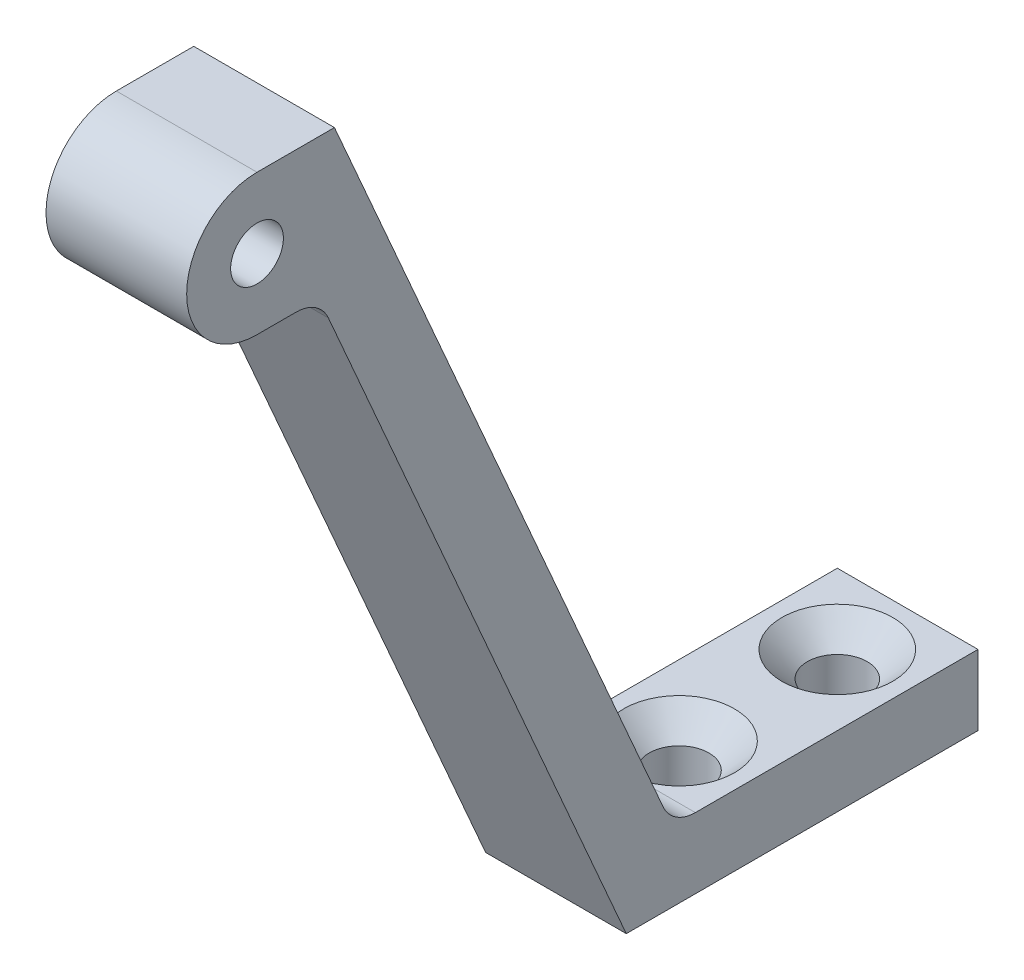
from build123d import *

# Parameters (mm, degrees)
SKETCH1_R                                       = 1.5
BOSS_EXTRUDE1_DEPTH                             = 4
CSK_FOR_M3_FLAT_HEAD_MACHINE_SCREW1_D           = 3.4
CSK_FOR_M3_FLAT_HEAD_MACHINE_SCREW1_DEPTH       = 7.5
CSK_FOR_M3_FLAT_HEAD_MACHINE_SCREW1_CSINK_D     = 6.3
CSK_FOR_M3_FLAT_HEAD_MACHINE_SCREW1_CSINK_ANGLE = 90
CSK_FOR_M3_FLAT_HEAD_MACHINE_SCREW1_TIP         = 1.021463052
FILLET1_R                                       = 2


with BuildPart() as part:
    # Sketch1 → Boss-Extrude1 (new body, symmetric)
    with BuildSketch(Plane(origin=(0, 0, 0), x_dir=(0, 0, -1), z_dir=(1, 0, 0))):
        with BuildLine():
            Line((0, -0.882843337), (0, 0))
            Line((0, 0), (0, 3.117156663))
            Line((0, 3.117156663), (-17.3820744, 3.117156663))
            Line((-17.3820744, 3.117156663), (-36.597884255, 47.117156663))
            Line((-36.597884255, 47.117156663), (-41, 47.117156663))
            ThreePointArc((-41, 47.117156663), (-45, 43.117156663), (-41, 39.117156663))
            Line((-41, 39.117156663), (-37.46891805, 39.117156663))
            Line((-37.46891805, 39.117156663), (-20, -0.882843337))
            Line((-20, -0.882843337), (0, -0.882843337))
        make_face()
        with Locations((-41, 43.117156663)):
            Circle(SKETCH1_R, mode=Mode.SUBTRACT)
    extrude(amount=BOSS_EXTRUDE1_DEPTH, both=True)

    # CSK for M3 Flat Head Machine Screw1
    with Locations(Plane(origin=(0, 3.117156663, 0), x_dir=(1, 0, 0), z_dir=(0, 1, 0))):
        with Locations((0, -13), (0, -4)):
            CounterSinkHole(CSK_FOR_M3_FLAT_HEAD_MACHINE_SCREW1_D / 2, CSK_FOR_M3_FLAT_HEAD_MACHINE_SCREW1_CSINK_D / 2, depth=CSK_FOR_M3_FLAT_HEAD_MACHINE_SCREW1_DEPTH, counter_sink_angle=CSK_FOR_M3_FLAT_HEAD_MACHINE_SCREW1_CSINK_ANGLE)
            with Locations((0, 0, -(CSK_FOR_M3_FLAT_HEAD_MACHINE_SCREW1_DEPTH + CSK_FOR_M3_FLAT_HEAD_MACHINE_SCREW1_TIP / 2))):  # 118° drill point
                Cone(0, CSK_FOR_M3_FLAT_HEAD_MACHINE_SCREW1_D / 2, CSK_FOR_M3_FLAT_HEAD_MACHINE_SCREW1_TIP, mode=Mode.SUBTRACT)

    # Fillet1
    fillet1_edges = [part.edges().sort_by_distance(p)[0] for p in [
        (0, 3.117156663, 17.3820744),
        (0, 39.117156663, 37.46891805),
    ]]
    fillet(fillet1_edges, radius=FILLET1_R)


solid = part.part
